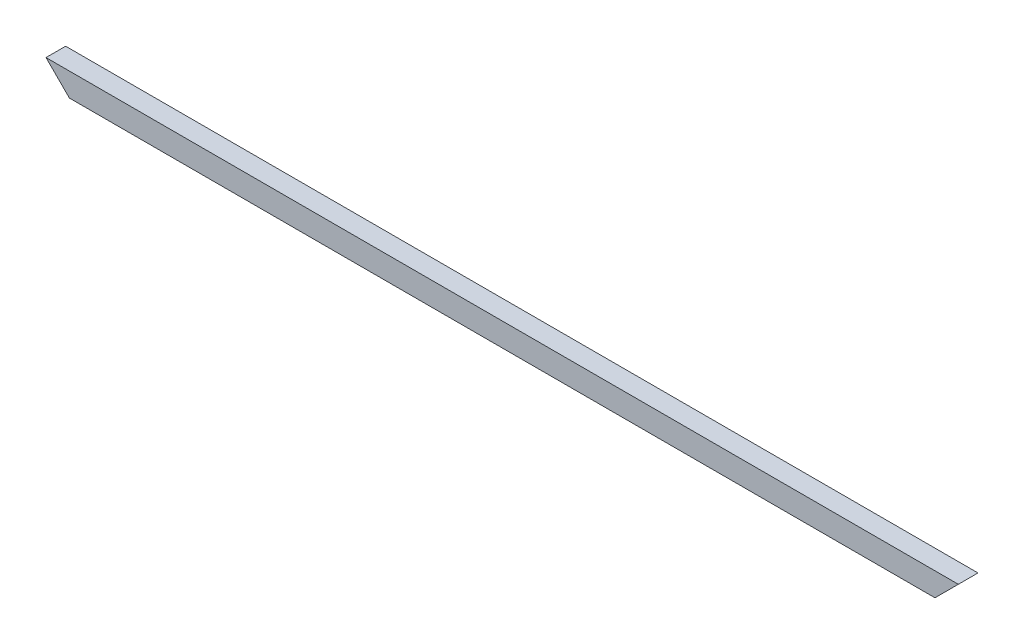
from build123d import *

# Parameters (mm, degrees)
BOSS_EXTRUDE1_DEPTH           = 371.475
CUT_RIGHT_SIDE_TOP_DEPTH      = 1
CUT_RIGHT_SIDE_TOP_DEPTH_BACK = 17
CUT_LEFT_SIDE_TOP_DEPTH       = 1
CUT_LEFT_SIDE_TOP_DEPTH_BACK  = 17


with BuildPart() as part:
    # Sketch1 → Boss-Extrude1 (new body, symmetric)
    with BuildSketch(Plane(origin=(0, 0, 0), x_dir=(0, 0, -1), z_dir=(1, 0, 0))):
        Polygon((-6.35, 0), (6.35, 0), (6.35, -17.4), (8, -17.4), (8, 1.65), (-8, 1.65), (-8, -17.4), (-6.35, -17.4), align=None)
    extrude(amount=BOSS_EXTRUDE1_DEPTH, both=True)

    # Sketch7 → Cut-Right-Side-Top (cut, two sides)
    with BuildSketch(Plane(origin=(0, 0, -8), x_dir=(-1, 0, 0), z_dir=(0, 0, -1))) as cut_right_side_top_sk:
        Polygon((-371.475, 1.65), (-352.425, -17.4), (-371.475, -17.4), align=None)
    extrude(amount=CUT_RIGHT_SIDE_TOP_DEPTH, mode=Mode.SUBTRACT)
    extrude(cut_right_side_top_sk.sketch, amount=-CUT_RIGHT_SIDE_TOP_DEPTH_BACK, mode=Mode.SUBTRACT)

    # Sketch5 → Cut-Left-Side-Top (cut, two sides)
    with BuildSketch(Plane(origin=(0, 0, -8), x_dir=(-1, 0, 0), z_dir=(0, 0, -1))) as cut_left_side_top_sk:
        Polygon((371.475, 1.65), (352.425, -17.4), (371.475, -17.4), align=None)
    extrude(amount=CUT_LEFT_SIDE_TOP_DEPTH, mode=Mode.SUBTRACT)
    extrude(cut_left_side_top_sk.sketch, amount=-CUT_LEFT_SIDE_TOP_DEPTH_BACK, mode=Mode.SUBTRACT)


solid = part.part
